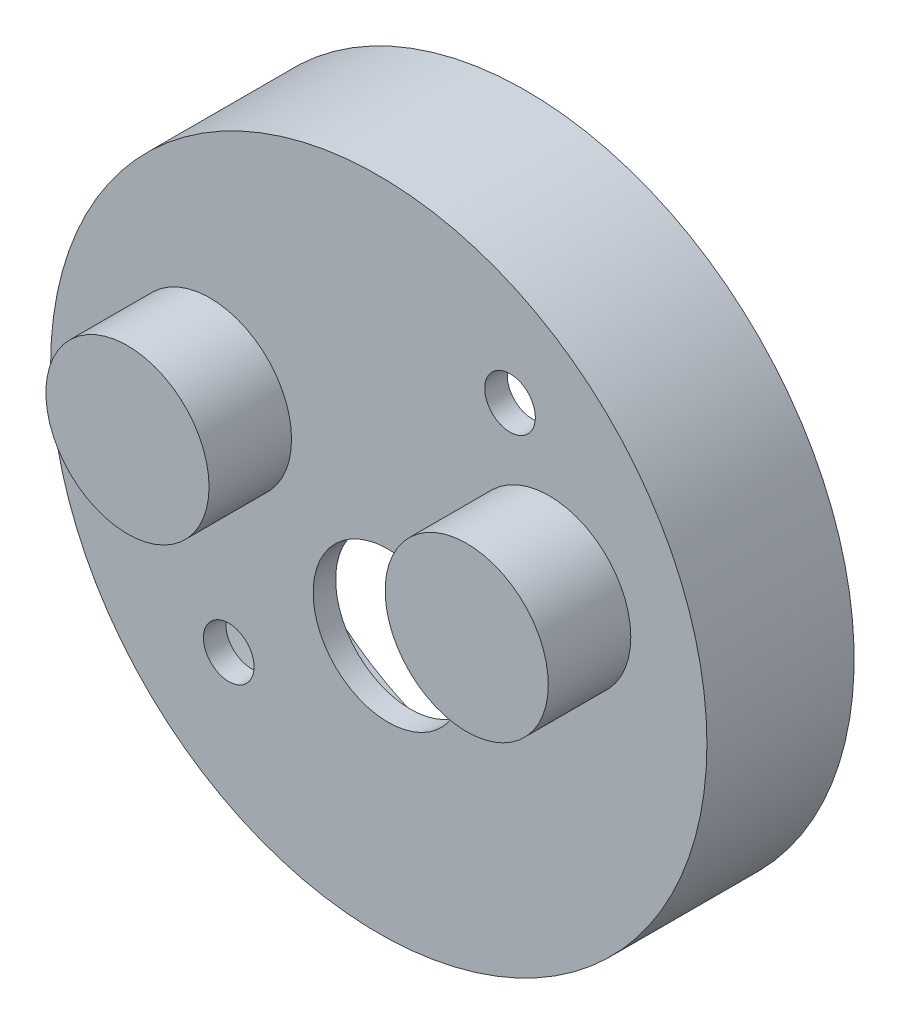
from build123d import *

# Parameters (mm, degrees)
SKETCH5_R           = 17.5
BOSS_EXTRUDE1_DEPTH = 5.85
SKETCH8_R           = 4.35
BOSS_EXTRUDE2_DEPTH = 10.25
SKETCH13_R          = 4
SKETCH13_R_2        = 1.35
SKETCH13_R_3        = 3.65
CUT_EXTRUDE1_DEPTH  = 9.55
SKETCH14_R          = 15.5
CUT_EXTRUDE2_DEPTH  = 4.65
BOSS_EXTRUDE3_START = 2
SKETCH15_R          = 17.5
BOSS_EXTRUDE3_DEPTH = 2


with BuildPart() as part:
    # Sketch5 → Boss-Extrude1 (new body)
    with BuildSketch(Plane.XY):
        with Locations((70.000455679, -49.499827976)):
            Circle(SKETCH5_R)
    extrude(amount=BOSS_EXTRUDE1_DEPTH)

    # Sketch8 → Boss-Extrude2 (add)
    with BuildSketch(Plane.XY):
        with Locations((79.090811, -46.590809)):
            Circle(SKETCH8_R)
        with Locations((61, -46.5)):
            Circle(SKETCH8_R)
    extrude(amount=BOSS_EXTRUDE2_DEPTH)

    # Sketch13 → Cut-Extrude1 (cut)
    with BuildSketch(Plane.XY):
        with Locations((70.5, -53)):
            Circle(SKETCH13_R)
        with Locations((77, -39.000037614)):
            Circle(SKETCH13_R_2)
        with Locations((62, -58.016959066)):
            Circle(SKETCH13_R_2)
        with Locations((79.090811, -46.590809)):
            Circle(SKETCH13_R_3)
        with Locations((61, -46.5)):
            Circle(SKETCH13_R_3)
    extrude(amount=CUT_EXTRUDE1_DEPTH, mode=Mode.SUBTRACT)

    # Sketch14 → Cut-Extrude2 (cut)
    with BuildSketch(Plane.XY):
        with Locations((70.000455679, -49.499827976)):
            Circle(SKETCH14_R)
    extrude(amount=CUT_EXTRUDE2_DEPTH, mode=Mode.SUBTRACT)

    # Sketch15 → Boss-Extrude3 (add)
    with BuildSketch(Plane(origin=(0, 0, 0), x_dir=(1, 0, 0), z_dir=(0, 0, -1)).offset(BOSS_EXTRUDE3_START)):
        with Locations((70.000455679, 49.499827976)):
            Circle(SKETCH15_R)
        with BuildLine():
            ThreePointArc((85.500455679, 49.499827976), (82.293609036, 40.059045139), (74.000019478, 34.524732336))
            ThreePointArc((74.000019478, 34.524732336), (70.000004184, 33.999827982), (66.000019478, 34.524965365))
            ThreePointArc((66.000019478, 34.524965365), (60.560030931, 61.793256324), (85.500455679, 49.499827976))
        make_face(mode=Mode.SUBTRACT)
    extrude(amount=-BOSS_EXTRUDE3_DEPTH)


solid = part.part
